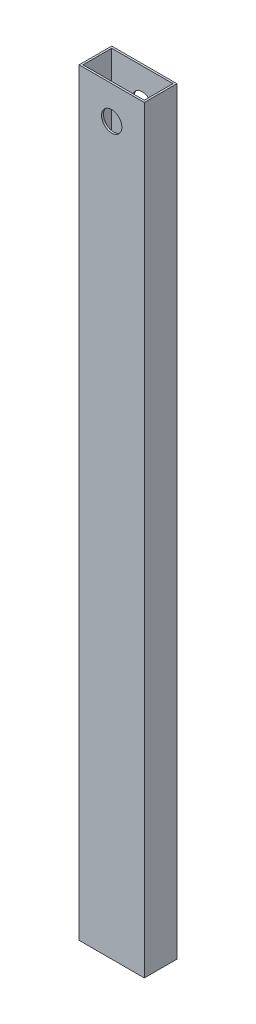
from build123d import *

# Parameters (mm, degrees)
SKETCH1_W           = 50.8
SKETCH1_H           = 25.4
SKETCH1_W_2         = 47.752
SKETCH1_H_2         = 22.352
BOSS_EXTRUDE2_DEPTH = 590.55
SKETCH2_R           = 7.9375
CUT_EXTRUDE1_DEPTH  = 26.4


with BuildPart() as part:
    # Sketch1 → Boss-Extrude2 (new body)
    with BuildSketch(Plane(origin=(0, 0, 0), x_dir=(1, 0, 0), z_dir=(0, 1, 0))):
        with Locations((-0.896470588, -8.665882353)):
            Rectangle(SKETCH1_W, SKETCH1_H)
        with Locations((-0.896470588, -8.665882353)):
            Rectangle(SKETCH1_W_2, SKETCH1_H_2, mode=Mode.SUBTRACT)
    extrude(amount=BOSS_EXTRUDE2_DEPTH)

    # Sketch2 → Cut-Extrude1 (cut, through all)
    with BuildSketch(Plane.XY.offset(21.365882353)):
        with Locations((-0.896470588, 565.15)):
            Circle(SKETCH2_R)
    extrude(amount=-CUT_EXTRUDE1_DEPTH, mode=Mode.SUBTRACT)


solid = part.part
